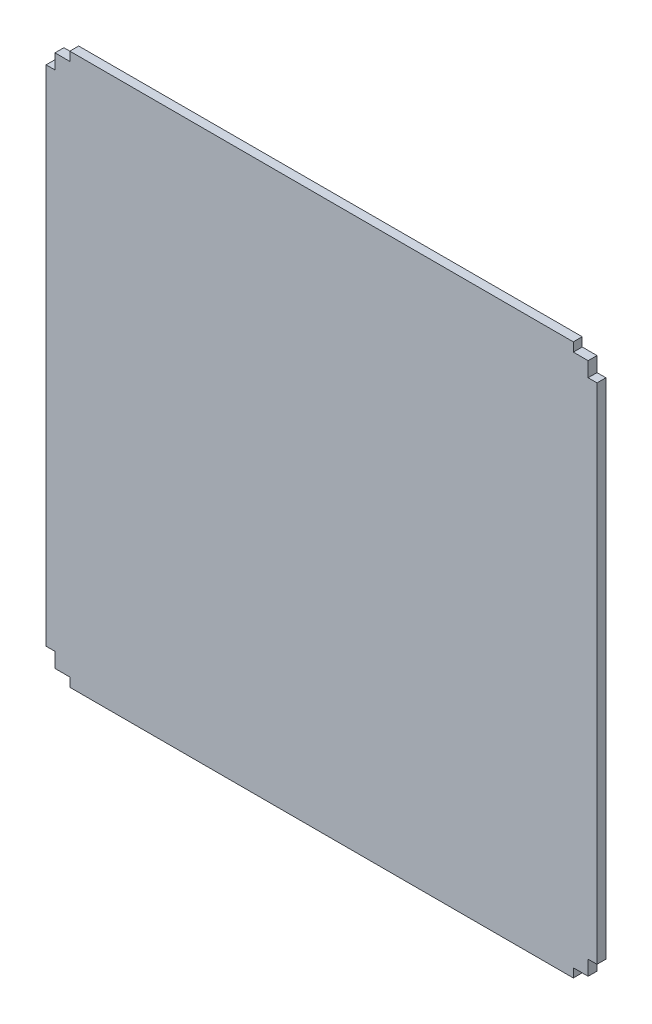
from build123d import *

# Parameters (mm, degrees)
EXTRUDE_1_DEPTH = 3


with BuildPart() as part:
    # 草图1 → 凸台-拉伸1 (new body)
    with BuildSketch(Plane.XY):
        Polygon((0, 180), (0, 175), (-3, 175), (-3, 5), (0, 5), (0, 0), (5, 0), (5, -3), (175, -3), (175, 0), (180, 0), (180, 5), (183, 5), (183, 175), (180, 175), (180, 180), (175, 180), (175, 183), (5, 183), (5, 180), align=None)
    extrude(amount=EXTRUDE_1_DEPTH)


solid = part.part
